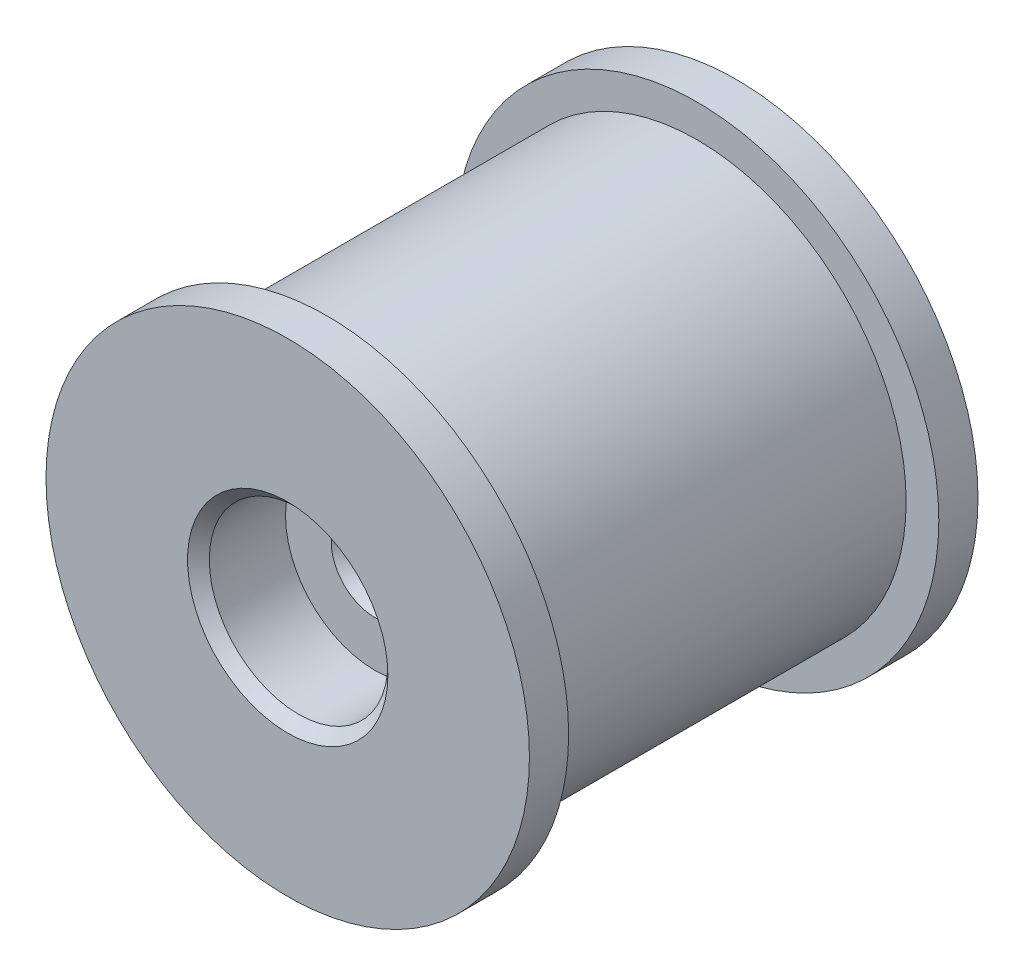
from build123d import *

# Parameters (mm, degrees)
AUFSATZ_LINEAR_AUSTRAGEN1_DEPTH      = 10.3
AUFSATZ_LINEAR_AUSTRAGEN1_DEPTH_BACK = 10.3
SKIZZE1_R                            = 9.6
SKIZZE2_R                            = 11.1
AUFSATZ_LINEAR_AUSTRAGEN2_DEPTH      = 1.8
AUFSATZ_LINEAR_START                 = -1.8
SKIZZE3_R                            = 11.1
AUFSATZ_LINEAR_AUSTRAGEN3_DEPTH      = 1.8
FASE1_SIZE                           = 0.5


with BuildPart() as part:
    # Skizze1 → Aufsatz-Linear austragen1 (new, two sides: drawn at the far end of the back side and taken through both)
    with BuildSketch(Plane.XY.offset(-AUFSATZ_LINEAR_AUSTRAGEN1_DEPTH_BACK)):
        Circle(SKIZZE1_R)
    extrude(amount=AUFSATZ_LINEAR_AUSTRAGEN1_DEPTH + AUFSATZ_LINEAR_AUSTRAGEN1_DEPTH_BACK)

    # Skizze2 → Aufsatz-Linear austragen2 (add)
    with BuildSketch(Plane.XY.offset(10.3)):
        Circle(SKIZZE2_R)
    extrude(amount=-AUFSATZ_LINEAR_AUSTRAGEN2_DEPTH)

    # Skizze3 → Aufsatz-Linear austragen3 (add)
    with BuildSketch(Plane(origin=(0, 0, -10.3), x_dir=(-1, 0, 0), z_dir=(0, 0, -1)).offset(AUFSATZ_LINEAR_START)):
        Circle(SKIZZE3_R)
    extrude(amount=AUFSATZ_LINEAR_AUSTRAGEN3_DEPTH)

    # Skizze8 → Schnitt-Rotation1 (revolve, cut)
    with BuildSketch(Plane(origin=(0, 0, 0), x_dir=(0, 0, -1), z_dir=(1, 0, 0))):
        Polygon((10.3, 0), (10.3, 8), (8.5, 8), (-2.7, 6), (-2.7, 1.5), (-6.3, 1.5), (-6.3, 4.1), (-10.3, 4.1), (-10.3, 0), align=None)
    revolve(axis=Axis((0, 0, -9.8), (0, 0, 1)), mode=Mode.SUBTRACT)

    # Fase1
    fase1_edges = [part.edges().sort_by_distance(p)[0] for p in [
        (0, -1.5, 6.3),
        (0, -1.5, 2.7),
        (0, -4.1, 10.3),
    ]]
    chamfer(fase1_edges, length=FASE1_SIZE)


solid = part.part
